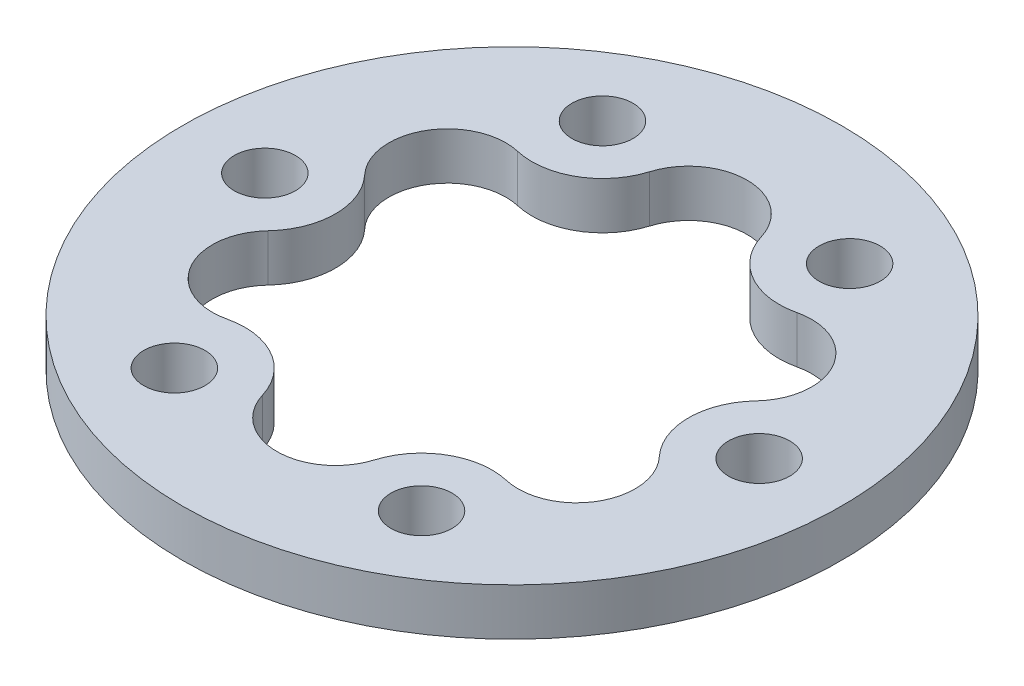
from build123d import *

# Parameters (mm, degrees)
SKETCH_1_R               = 28
SKETCH_1_R_2             = 2.6
EXTRUDE_1_DEPTH          = 4
CUT_EXTRUDE_2_DEPTH      = 1
CUT_EXTRUDE_2_DEPTH_BACK = 5


with BuildPart() as part:
    # 草图1 → 凸台-拉伸1 (new body)
    with BuildSketch(Plane(origin=(0, 0, 0), x_dir=(1, 0, 0), z_dir=(0, 1, 0))):
        Circle(SKETCH_1_R)
        with Locations((10.5, 18.186533479)):
            Circle(SKETCH_1_R_2, mode=Mode.SUBTRACT)
        with Locations((21, 0)):
            Circle(SKETCH_1_R_2, mode=Mode.SUBTRACT)
        with Locations((10.5, -18.186533479)):
            Circle(SKETCH_1_R_2, mode=Mode.SUBTRACT)
        with Locations((-10.5, -18.186533479)):
            Circle(SKETCH_1_R_2, mode=Mode.SUBTRACT)
        with Locations((-21, 0)):
            Circle(SKETCH_1_R_2, mode=Mode.SUBTRACT)
        with Locations((-10.5, 18.186533479)):
            Circle(SKETCH_1_R_2, mode=Mode.SUBTRACT)
    extrude(amount=EXTRUDE_1_DEPTH)

    # 草图4 → 切除-拉伸2 (cut, two sides)
    with BuildSketch(Plane(origin=(0, 4, 0), x_dir=(1, 0, 0), z_dir=(0, 1, 0))) as cut_extrude_2_sk:
        with BuildLine():
            ThreePointArc((4.758569662, 16.444127766), (7.499999998, 12.990381058), (11.861747553, 12.343106095))
            ThreePointArc((11.861747553, 12.343106095), (17.297017524, 9.986437726), (16.620317219, 4.10102167))
            ThreePointArc((16.620317219, 4.10102167), (15, 2e-09), (16.620317216, -4.101021667))
            ThreePointArc((16.620317216, -4.101021667), (17.297017526, -9.986437723), (11.861747557, -12.343106096))
            ThreePointArc((11.861747557, -12.343106096), (7.500000002, -12.990381056), (4.758569663, -16.444127762))
            ThreePointArc((4.758569663, -16.444127762), (2e-09, -19.972875449), (-4.758569662, -16.444127766))
            ThreePointArc((-4.758569662, -16.444127766), (-7.499999998, -12.990381058), (-11.861747553, -12.343106095))
            ThreePointArc((-11.861747553, -12.343106095), (-17.297017524, -9.986437726), (-16.620317219, -4.10102167))
            ThreePointArc((-16.620317219, -4.10102167), (-15, -2e-09), (-16.620317216, 4.101021667))
            ThreePointArc((-16.620317216, 4.101021667), (-17.297017526, 9.986437723), (-11.861747557, 12.343106096))
            ThreePointArc((-11.861747557, 12.343106096), (-7.500000002, 12.990381056), (-4.758569663, 16.444127762))
            ThreePointArc((-4.758569663, 16.444127762), (-2e-09, 19.972875449), (4.758569662, 16.444127766))
        make_face()
    extrude(amount=CUT_EXTRUDE_2_DEPTH, mode=Mode.SUBTRACT)
    extrude(cut_extrude_2_sk.sketch, amount=-CUT_EXTRUDE_2_DEPTH_BACK, mode=Mode.SUBTRACT)


solid = part.part
